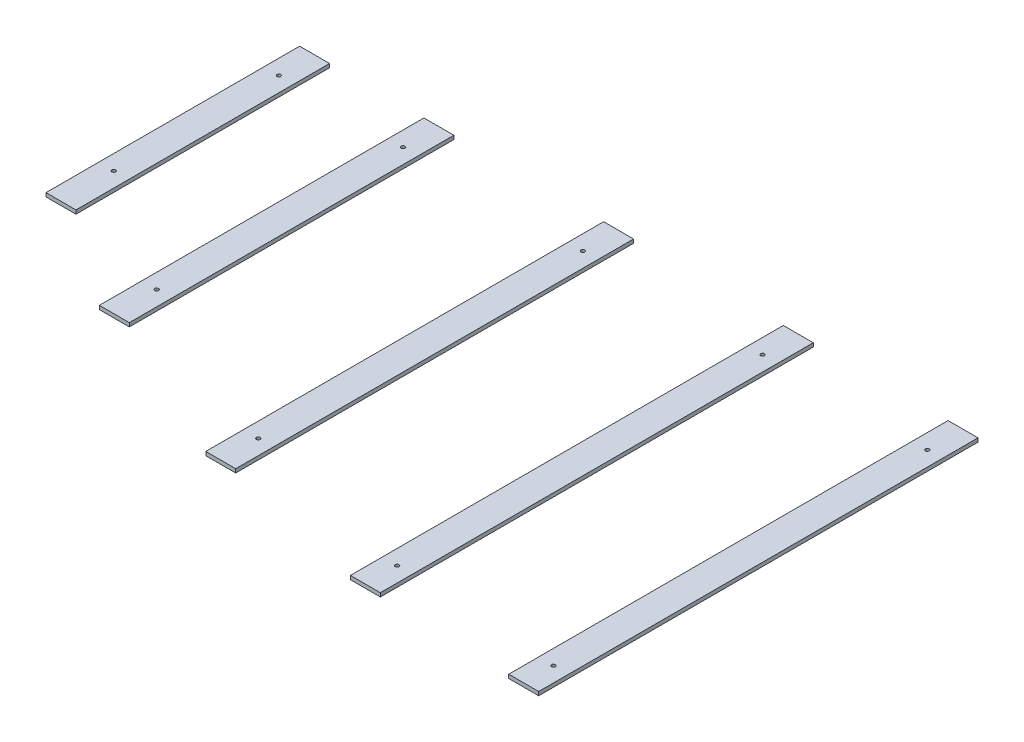
from build123d import *

# Parameters (mm, degrees)
SKETCH4_W             = 200
SKETCH4_H             = 2933.573874127
SKETCH4_R             = 12.5
BOSS_EXTRUDE1_DEPTH   = 25
SKETCH4_H_2           = 2891.000919938
BOSS_EXTRUDE1_2_DEPTH = 25
SKETCH4_H_3           = 2656.8496719
BOSS_EXTRUDE1_3_DEPTH = 25
SKETCH4_H_4           = 2167.26069873
BOSS_EXTRUDE1_4_DEPTH = 25
SKETCH4_H_5           = 1693.636583381
BOSS_EXTRUDE1_5_DEPTH = 25


with BuildPart() as part:
    # Sketch4 → Boss-Extrude1 (new body)
    with BuildSketch(Plane(origin=(0, 0, 0), x_dir=(1, 0, 0), z_dir=(0, 1, 0))):
        with Locations((23132.944645813, -11409.369811035)):
            Rectangle(SKETCH4_W, SKETCH4_H)
        with Locations((23132.944645813, -12678.089615367)):
            Circle(SKETCH4_R, mode=Mode.SUBTRACT)
        with Locations((23132.944645813, -10181.030459334)):
            Circle(SKETCH4_R, mode=Mode.SUBTRACT)
    extrude(amount=BOSS_EXTRUDE1_DEPTH)


with BuildPart() as body_2:
    # Sketch4 → Boss-Extrude1 2 (new body)
    with BuildSketch(Plane(origin=(0, 0, 0), x_dir=(1, 0, 0), z_dir=(0, 1, 0))):
        with Locations((22032.944645813, -11388.083333941)):
            Rectangle(SKETCH4_W, SKETCH4_H_2)
        with Locations((22032.944645813, -12621.228285175)):
            Circle(SKETCH4_R, mode=Mode.SUBTRACT)
        with Locations((22032.944645813, -10181.030459334)):
            Circle(SKETCH4_R, mode=Mode.SUBTRACT)
    extrude(amount=BOSS_EXTRUDE1_2_DEPTH)


with BuildPart() as body_3:
    # Sketch4 → Boss-Extrude1 3 (new body)
    with BuildSketch(Plane(origin=(0, 0, 0), x_dir=(1, 0, 0), z_dir=(0, 1, 0))):
        with Locations((20832.944645813, -11271.007709922)):
            Rectangle(SKETCH4_W, SKETCH4_H_3)
        with Locations((20832.944645813, -12348.754240871)):
            Circle(SKETCH4_R, mode=Mode.SUBTRACT)
        with Locations((20832.944645813, -10181.030459334)):
            Circle(SKETCH4_R, mode=Mode.SUBTRACT)
    extrude(amount=BOSS_EXTRUDE1_3_DEPTH)


with BuildPart() as body_4:
    # Sketch4 → Boss-Extrude1 4 (new body)
    with BuildSketch(Plane(origin=(0, 0, 0), x_dir=(1, 0, 0), z_dir=(0, 1, 0))):
        with Locations((19632.944645813, -11026.213223337)):
            Rectangle(SKETCH4_W, SKETCH4_H_4)
        with Locations((19632.944645813, -11826.915448153)):
            Circle(SKETCH4_R, mode=Mode.SUBTRACT)
        with Locations((19632.944645813, -10181.030459334)):
            Circle(SKETCH4_R, mode=Mode.SUBTRACT)
    extrude(amount=BOSS_EXTRUDE1_4_DEPTH)


with BuildPart() as body_5:
    # Sketch4 → Boss-Extrude1 5 (new body)
    with BuildSketch(Plane(origin=(0, 0, 0), x_dir=(1, 0, 0), z_dir=(0, 1, 0))):
        with Locations((18802.944645813, -10789.401165663)):
            Rectangle(SKETCH4_W, SKETCH4_H_5)
        with Locations((18802.944645813, -11283.669778774)):
            Circle(SKETCH4_R, mode=Mode.SUBTRACT)
        with Locations((18802.944645813, -10181.030459334)):
            Circle(SKETCH4_R, mode=Mode.SUBTRACT)
    extrude(amount=BOSS_EXTRUDE1_5_DEPTH)


solid = Compound([part.part, body_2.part, body_3.part, body_4.part, body_5.part])
